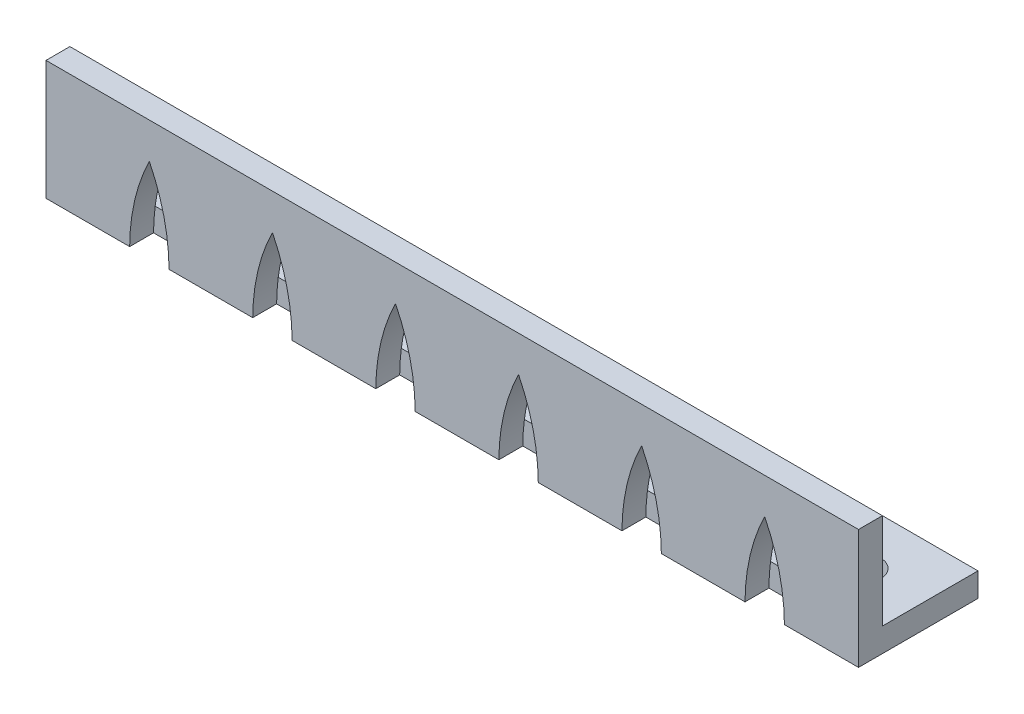
from build123d import *

# Parameters (mm, degrees)
SKETCH1_W                      = 68
SKETCH1_H                      = 10
SKETCH1_R                      = 1.5025
BOSS_EXTRUDE1_DEPTH            = 10
CUT_EXTRUDE1_REACH             = 7
SKETCH2_W                      = 68
SKETCH2_H                      = 8
CUT_EXTRUDE1_DIRECTION_2_DEPTH = 3
CUT_EXTRUDE2_DEPTH             = 2


with BuildPart() as part:
    # Sketch1 → Boss-Extrude1 (new body)
    with BuildSketch(Plane(origin=(0, 0, 0), x_dir=(1, 0, 0), z_dir=(0, 1, 0))):
        Rectangle(SKETCH1_W, SKETCH1_H)
        with Locations((-31, 0.35)):
            Circle(SKETCH1_R, mode=Mode.SUBTRACT)
        with Locations((-21, 0.35)):
            Circle(SKETCH1_R, mode=Mode.SUBTRACT)
        with Locations((-11, 0.35)):
            Circle(SKETCH1_R, mode=Mode.SUBTRACT)
        with Locations((-1, 0.35)):
            Circle(SKETCH1_R, mode=Mode.SUBTRACT)
        with Locations((9, 0.35)):
            Circle(SKETCH1_R, mode=Mode.SUBTRACT)
        with Locations((19, 0.35)):
            Circle(SKETCH1_R, mode=Mode.SUBTRACT)
        with Locations((29, 0.35)):
            Circle(SKETCH1_R, mode=Mode.SUBTRACT)
    extrude(amount=BOSS_EXTRUDE1_DEPTH)

    # Sketch2 → Cut-Extrude1 (cut, up to next)
    with BuildSketch(Plane.XY, mode=Mode.PRIVATE) as cut_extrude1_sk1:
        with Locations((0, 6)):
            Rectangle(SKETCH2_W, SKETCH2_H)
    cut_extrude1_tool1 = extrude(cut_extrude1_sk1.sketch, amount=-CUT_EXTRUDE1_REACH, mode=Mode.PRIVATE) & part.part
    add(cut_extrude1_tool1.solids().sort_by_distance((0, 6, 0))[0], mode=Mode.SUBTRACT)

    # Sketch2 → Cut-Extrude1 direction 2 (cut)
    with BuildSketch(Plane.XY):
        with Locations((0, 6)):
            Rectangle(SKETCH2_W, SKETCH2_H)
    extrude(amount=CUT_EXTRUDE1_DIRECTION_2_DEPTH, mode=Mode.SUBTRACT)

    # Sketch3 → Cut-Extrude2 (cut)
    with BuildSketch(Plane.XY.offset(5)):
        with BuildLine():
            Line((-27, 0), (-23.7, 0))
            add(Edge.make_bspline(
                [(-25.35, 7), (-23.734888234, 3.724961413), (-23.7, 0)],
                knots=[0, 0, 0, 1, 1, 1], degree=2))
            add(Edge.make_bspline(
                [(-25.35, 7), (-26.965111766, 3.724961413), (-27, 0)],
                knots=[0, 0, 0, 1, 1, 1], degree=2))
        make_face()
        with BuildLine():
            Line((-16.7, 0), (-13.4, 0))
            add(Edge.make_bspline(
                [(-15.05, 7), (-13.434888234, 3.724961413), (-13.4, 0)],
                knots=[0, 0, 0, 1, 1, 1], degree=2))
            add(Edge.make_bspline(
                [(-15.05, 7), (-16.665111766, 3.724961413), (-16.7, 0)],
                knots=[0, 0, 0, 1, 1, 1], degree=2))
        make_face()
        with BuildLine():
            Line((-6.4, 0), (-3.1, 0))
            add(Edge.make_bspline(
                [(-4.75, 7), (-3.134888234, 3.724961413), (-3.1, 0)],
                knots=[0, 0, 0, 1, 1, 1], degree=2))
            add(Edge.make_bspline(
                [(-4.75, 7), (-6.365111766, 3.724961413), (-6.4, 0)],
                knots=[0, 0, 0, 1, 1, 1], degree=2))
        make_face()
        with BuildLine():
            Line((3.9, 0), (7.2, 0))
            add(Edge.make_bspline(
                [(5.55, 7), (7.165111766, 3.724961413), (7.2, 0)],
                knots=[0, 0, 0, 1, 1, 1], degree=2))
            add(Edge.make_bspline(
                [(5.55, 7), (3.934888234, 3.724961413), (3.9, 0)],
                knots=[0, 0, 0, 1, 1, 1], degree=2))
        make_face()
        with BuildLine():
            Line((14.2, 0), (17.5, 0))
            add(Edge.make_bspline(
                [(15.85, 7), (17.465111766, 3.724961413), (17.5, 0)],
                knots=[0, 0, 0, 1, 1, 1], degree=2))
            add(Edge.make_bspline(
                [(15.85, 7), (14.234888234, 3.724961413), (14.2, 0)],
                knots=[0, 0, 0, 1, 1, 1], degree=2))
        make_face()
        with BuildLine():
            Line((24.5, 0), (27.8, 0))
            add(Edge.make_bspline(
                [(26.15, 7), (27.765111766, 3.724961413), (27.8, 0)],
                knots=[0, 0, 0, 1, 1, 1], degree=2))
            add(Edge.make_bspline(
                [(26.15, 7), (24.534888234, 3.724961413), (24.5, 0)],
                knots=[0, 0, 0, 1, 1, 1], degree=2))
        make_face()
    extrude(amount=-CUT_EXTRUDE2_DEPTH, mode=Mode.SUBTRACT)


solid = part.part
